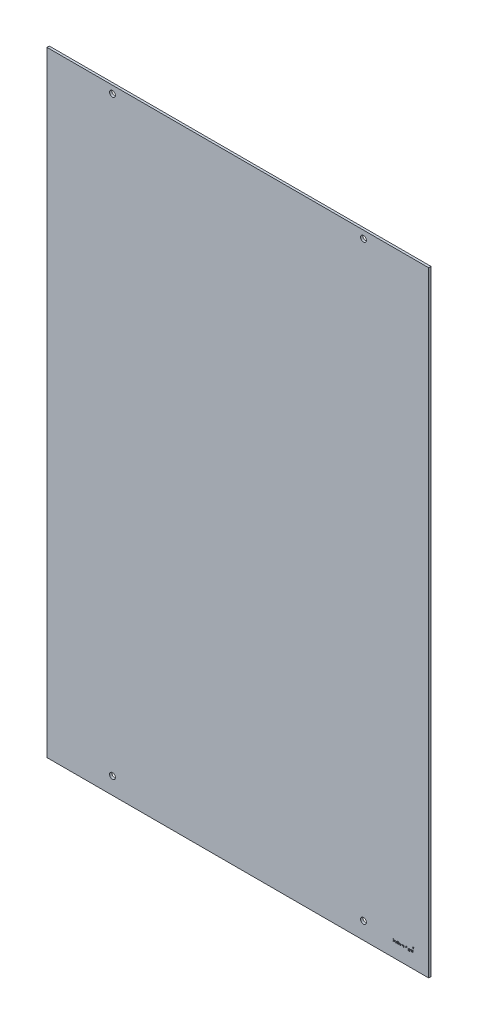
from build123d import *

# Parameters (mm, degrees)
SKETCH1_W           = 502.7676
SKETCH1_H           = 810.1076
BOSS_EXTRUDE1_DEPTH = 3.0734
SKETCH2_R           = 3.81
CUT_EXTRUDE1_DEPTH  = 4.0734
SKETCH3_W           = 0.284935897
SKETCH3_H           = 2.320192308
CUT_EXTRUDE2_DEPTH  = 1.27


with BuildPart() as part:
    # Sketch1 → Boss-Extrude1 (new body)
    with BuildSketch(Plane.XY):
        Rectangle(SKETCH1_W, SKETCH1_H)
    extrude(amount=BOSS_EXTRUDE1_DEPTH)

    # Sketch2 → Cut-Extrude1 (cut, through all)
    with BuildSketch(Plane(origin=(0, 0, 0), x_dir=(-1, 0, 0), z_dir=(0, 0, -1))):
        with Locations((-165.481, 395.1478)):
            Circle(SKETCH2_R)
        with Locations((165.1254, 395.1478)):
            Circle(SKETCH2_R)
        with Locations((165.1254, -382.8288)):
            Circle(SKETCH2_R)
        with Locations((-165.481, -382.8288)):
            Circle(SKETCH2_R)
    extrude(amount=-CUT_EXTRUDE1_DEPTH, mode=Mode.SUBTRACT)

    # Sketch3 → Cut-Extrude2 (cut)
    with BuildSketch(Plane.XY.offset(3.0734)):
        Polygon((231.0638, -379.564469266), (230.0478, -380.834469266), (230.5558, -380.834469266), (230.5558, -382.104469266), (231.5718, -382.104469266), (231.5718, -380.834469266), (232.0798, -380.834469266), align=None)
        Polygon((230.208992308, -383.382389744), (230.493928205, -383.382389744), (230.493928205, -384.318607692), (230.900979487, -384.318607692), (230.900979487, -384.60354359), (230.493928205, -384.60354359), (230.493928205, -386.6388), (230.208992308, -386.6388), (230.208992308, -384.60354359), (229.801941026, -384.60354359), (229.801941026, -384.318607692), (230.208992308, -384.318607692), align=None)
        with BuildLine():
            Line((227.237517949, -383.382389744), (227.522453846, -383.382389744))
            Line((227.522453846, -383.382389744), (227.522453846, -384.756823838))
            add(Edge.make_bspline(
                [(227.522453846, -384.756823838), (227.553040256, -384.718593226), (227.612593562, -384.644156265), (227.712829325, -384.54703647), (227.815763616, -384.462854864), (227.924951693, -384.395843806), (228.03839038, -384.342906085), (228.156558114, -384.305361577), (228.279476852, -384.282273796), (228.36295681, -384.279372374), (228.405246314, -384.277902564)],
                knots=[0, 0, 0, 0, 0.000146744, 0.000285718, 0.000417826, 0.00054491, 0.000668979, 0.000792481, 0.000915983, 0.001042781, 0.001042781, 0.001042781, 0.001042781], degree=3))
            add(Edge.make_bspline(
                [(228.405246314, -384.277902564), (228.448181742, -384.279485919), (228.532216731, -384.282584926), (228.654573486, -384.307089921), (228.768837994, -384.348961311), (228.87467058, -384.406262827), (228.969761555, -384.47763032), (229.053989556, -384.560027487), (229.122787995, -384.65552597), (229.169595765, -384.743751286), (229.200051642, -384.822254299), (229.219330085, -384.889597421), (229.235676072, -384.964638013), (229.249917975, -385.047337449), (229.259409938, -385.138092712), (229.267034127, -385.236494357), (229.272455625, -385.342536743), (229.272665723, -385.415942969), (229.272774359, -385.453899159)],
                knots=[0, 0, 0, 0, 0.000128741, 0.000251978, 0.000372501, 0.000492599, 0.000611662, 0.000728143, 0.000844672, 0.000963309, 0.001026736, 0.001096978, 0.001173207, 0.001257065, 0.001348583, 0.001446826, 0.001553163, 0.001667017, 0.001667017, 0.001667017, 0.001667017], degree=3))
            Line((229.272774359, -385.453899159), (229.272774359, -386.6388))
            Line((229.272774359, -386.6388), (228.987838462, -386.6388))
            Line((228.987838462, -386.6388), (228.987838462, -385.54739375))
            add(Edge.make_bspline(
                [(228.987838462, -385.54739375), (228.987665829, -385.515804614), (228.987335613, -385.455379973), (228.986244008, -385.368869289), (228.983807227, -385.290404938), (228.979869478, -385.220238389), (228.975728092, -385.158271821), (228.970028226, -385.104595221), (228.963396799, -385.059134868), (228.957437976, -385.031771241), (228.954765545, -385.019499119)],
                knots=[0, 0, 0, 0, 9.4769e-05, 0.000181277, 0.000259548, 0.000330249, 0.000392103, 0.000445834, 0.000492159, 0.000529829, 0.000529829, 0.000529829, 0.000529829], degree=3))
            add(Edge.make_bspline(
                [(228.954765545, -385.019499119), (228.944402123, -384.983490751), (228.924478503, -384.914264874), (228.878170696, -384.820228259), (228.820332164, -384.740050672), (228.749713577, -384.67481414), (228.667564204, -384.623640815), (228.573348379, -384.588200755), (228.467952831, -384.566204607), (228.393701853, -384.563991811), (228.355000921, -384.562838462)],
                knots=[0, 0, 0, 0, 0.000112235, 0.000215771, 0.000312707, 0.000407219, 0.000502346, 0.000601207, 0.000707732, 0.000823699, 0.000823699, 0.000823699, 0.000823699], degree=3))
            add(Edge.make_bspline(
                [(228.355000921, -384.562838462), (228.332079442, -384.563270104), (228.286718425, -384.564124313), (228.219454992, -384.57270035), (228.154205056, -384.586714544), (228.090340223, -384.605677947), (228.029214037, -384.631482113), (227.969044771, -384.661354499), (227.911537167, -384.697919844), (227.855670033, -384.738946076), (227.803674842, -384.784366501), (227.75529953, -384.832306239), (227.712175464, -384.883355671), (227.6731061, -384.936695776), (227.639380083, -384.993058189), (227.609940502, -385.051899392), (227.584961692, -385.113296767), (227.572549535, -385.155909858), (227.566339062, -385.17723149)],
                knots=[0, 0, 0, 0, 6.8737e-05, 0.000136029, 0.000203016, 0.000268809, 0.000335543, 0.000401817, 0.000470111, 0.000539693, 0.000609577, 0.000677037, 0.000743816, 0.000809842, 0.000875179, 0.000940599, 0.001007093, 0.001073681, 0.001073681, 0.001073681, 0.001073681], degree=3))
            add(Edge.make_bspline(
                [(227.566339062, -385.17723149), (227.562765439, -385.192671924), (227.554978074, -385.226318531), (227.54652819, -385.281812382), (227.538964617, -385.346297876), (227.532570576, -385.419677207), (227.528648919, -385.502219262), (227.524423229, -385.593360775), (227.52285023, -385.693672651), (227.522589923, -385.763427861), (227.522453846, -385.799892748)],
                knots=[0, 0, 0, 0, 4.7531e-05, 0.000103577, 0.000168266, 0.000242318, 0.000324485, 0.000416151, 0.000516024, 0.000625421, 0.000625421, 0.000625421, 0.000625421], degree=3))
            Line((227.522453846, -385.799892748), (227.522453846, -386.6388))
            Line((227.522453846, -386.6388), (227.237517949, -386.6388))
            Line((227.237517949, -386.6388), (227.237517949, -383.382389744))
        make_face()
        with BuildLine():
            Line((226.3013, -384.318607692), (226.586235897, -384.318607692))
            Line((226.586235897, -384.318607692), (226.586235897, -386.159878726))
            add(Edge.make_bspline(
                [(226.586235897, -386.159878726), (226.58598458, -386.199101401), (226.585499478, -386.274810612), (226.582006096, -386.384283051), (226.574639482, -386.485398715), (226.566285893, -386.578618764), (226.554269229, -386.663511106), (226.539594953, -386.740329056), (226.523052586, -386.809146331), (226.508519961, -386.851532436), (226.501645553, -386.871582452)],
                knots=[0, 0, 0, 0, 0.00011767, 0.000227132, 0.0003285, 0.000421785, 0.000507864, 0.000585575, 0.000656379, 0.000719936, 0.000719936, 0.000719936, 0.000719936], degree=3))
            add(Edge.make_bspline(
                [(226.501645553, -386.871582452), (226.491495315, -386.897644595), (226.471498324, -386.94898964), (226.434046357, -387.021773631), (226.392105602, -387.090304999), (226.344202335, -387.15420183), (226.290553177, -387.213143358), (226.232422109, -387.268410128), (226.168677007, -387.318832909), (226.099354318, -387.363541714), (226.026052065, -387.403807113), (225.948812387, -387.438683642), (225.868070832, -387.469060993), (225.783068923, -387.491814672), (225.695139353, -387.511531169), (225.603248112, -387.524362419), (225.507932075, -387.533095536), (225.443120909, -387.533903105), (225.410239303, -387.534312821)],
                knots=[0, 0, 0, 0, 8.3858e-05, 0.000165209, 0.000245167, 0.00032467, 0.000404375, 0.000484009, 0.000565064, 0.0006478, 0.000731198, 0.000815733, 0.000901862, 0.000989664, 0.001079485, 0.00117204, 0.0012678, 0.001366416, 0.001366416, 0.001366416, 0.001366416], degree=3))
            add(Edge.make_bspline(
                [(225.410239303, -387.534312821), (225.362265294, -387.533535866), (225.268559164, -387.532018264), (225.131938921, -387.514337219), (225.002185997, -387.489341467), (224.881014882, -387.451508686), (224.769191294, -387.405210845), (224.667478922, -387.352056852), (224.576790845, -387.291106551), (224.495035799, -387.221709577), (224.421247357, -387.139192523), (224.351826172, -387.041947857), (224.285005175, -386.928494322), (224.245845054, -386.845225218), (224.225338462, -386.801620513)],
                knots=[0, 0, 0, 0, 0.00014383, 0.000280939, 0.000412657, 0.0005398, 0.000660986, 0.000775358, 0.000883492, 0.000988144, 0.001096214, 0.001214661, 0.001346101, 0.001490599, 0.001490599, 0.001490599, 0.001490599], degree=3))
            Line((224.225338462, -386.801620513), (224.510274359, -386.801620513))
            add(Edge.make_bspline(
                [(224.510274359, -386.801620513), (224.533190792, -386.838002272), (224.577989596, -386.90912413), (224.661762861, -387.001211064), (224.753571457, -387.079908759), (224.856513741, -387.143327819), (224.971018043, -387.191143129), (225.097153251, -387.225229291), (225.235945765, -387.245636619), (225.332573003, -387.24809615), (225.382890545, -387.249376923)],
                knots=[0, 0, 0, 0, 0.000128773, 0.000251735, 0.000371772, 0.000490565, 0.000612829, 0.000742746, 0.000881626, 0.001032524, 0.001032524, 0.001032524, 0.001032524], degree=3))
            add(Edge.make_bspline(
                [(225.382890545, -387.249376923), (225.432571938, -387.248079574), (225.528352692, -387.245578414), (225.666085252, -387.225220184), (225.79181066, -387.191135711), (225.904804557, -387.14341239), (226.003733718, -387.084946664), (226.089016025, -387.01963231), (226.158090124, -386.945989543), (226.204547601, -386.878151762), (226.233426146, -386.817714159), (226.251815961, -386.765687161), (226.266760205, -386.706856336), (226.279260486, -386.641418919), (226.289575529, -386.569281415), (226.296109572, -386.490278885), (226.300831987, -386.404590876), (226.301140388, -386.345179244), (226.3013, -386.31443101)],
                knots=[0, 0, 0, 0, 0.000148992, 0.000287243, 0.000416547, 0.000538811, 0.000653999, 0.000760488, 0.000859928, 0.000955714, 0.001005782, 0.001060502, 0.001120973, 0.001187707, 0.001260294, 0.00133947, 0.001425447, 0.001517679, 0.001517679, 0.001517679, 0.001517679], degree=3))
            Line((226.3013, -386.31443101), (226.3013, -386.194223678))
            add(Edge.make_bspline(
                [(226.3013, -386.194223678), (226.272379272, -386.228642313), (226.215046523, -386.296874169), (226.116034305, -386.386283654), (226.007887531, -386.463287501), (225.890790318, -386.526441548), (225.767610984, -386.576952554), (225.639683675, -386.612279383), (225.508155168, -386.635103007), (225.419026432, -386.637558929), (225.373986298, -386.6388)],
                knots=[0, 0, 0, 0, 0.000134741, 0.000267112, 0.00039894, 0.000532134, 0.000665359, 0.000797455, 0.00092962, 0.001064637, 0.001064637, 0.001064637, 0.001064637], degree=3))
            add(Edge.make_bspline(
                [(225.373986298, -386.6388), (225.347464825, -386.638332797), (225.294735734, -386.637403921), (225.216399641, -386.62927703), (225.13921953, -386.617485314), (225.063375398, -386.600175723), (224.988757807, -386.577958228), (224.915490062, -386.550184472), (224.842978935, -386.518783615), (224.772542469, -386.481796858), (224.704882193, -386.440646765), (224.640508446, -386.396070771), (224.579758415, -386.348302181), (224.523210313, -386.296869957), (224.470938319, -386.241848538), (224.422239381, -386.183824458), (224.377918788, -386.121987485), (224.33706707, -386.057465174), (224.301636293, -385.989827764), (224.270535469, -385.920541921), (224.243494081, -385.849755791), (224.221935466, -385.777232384), (224.205469813, -385.703017422), (224.193214108, -385.627232486), (224.186262734, -385.549644206), (224.185178767, -385.497373411), (224.184633333, -385.471071635)],
                knots=[0, 0, 0, 0, 7.9543e-05, 0.000158144, 0.000236046, 0.000313655, 0.000391328, 0.000469416, 0.000548589, 0.000628244, 0.00070787, 0.000786028, 0.00086301, 0.000939549, 0.001015125, 0.001090533, 0.001166614, 0.0012432, 0.001319448, 0.001395457, 0.00147094, 0.001546602, 0.00162221, 0.001698855, 0.001776764, 0.001855671, 0.001855671, 0.001855671, 0.001855671], degree=3))
            add(Edge.make_bspline(
                [(224.184633333, -385.471071635), (224.185104291, -385.444761683), (224.186044383, -385.392243683), (224.1941642, -385.314338812), (224.205746772, -385.23747711), (224.224078105, -385.162450824), (224.246142108, -385.088405514), (224.273468492, -385.0158881), (224.30632408, -384.944876495), (224.343525782, -384.875318113), (224.385330637, -384.808146348), (224.431170816, -384.744350033), (224.481101659, -384.68439862), (224.534434326, -384.627687295), (224.591820017, -384.574763226), (224.653229046, -384.525754865), (224.718056087, -384.479840712), (224.786502057, -384.438011142), (224.857510831, -384.401015819), (224.929278365, -384.367258677), (225.002755336, -384.340467012), (225.076571854, -384.316860343), (225.152027919, -384.300136987), (225.22819834, -384.287235382), (225.30534389, -384.279375242), (225.357008302, -384.27839409), (225.382890545, -384.277902564)],
                knots=[0, 0, 0, 0, 7.8907e-05, 0.000157509, 0.000234782, 0.000311916, 0.000388979, 0.000466471, 0.000544164, 0.000623555, 0.000702973, 0.000781345, 0.000859033, 0.000936869, 0.001014737, 0.001093008, 0.001172416, 0.001252917, 0.00133343, 0.001412545, 0.001490633, 0.001567882, 0.001644872, 0.001722247, 0.001799582, 0.001877218, 0.001877218, 0.001877218, 0.001877218], degree=3))
            add(Edge.make_bspline(
                [(225.382890545, -384.277902564), (225.425572468, -384.279133261), (225.509856152, -384.281563508), (225.633890704, -384.30063269), (225.753581164, -384.331034688), (225.869602936, -384.374591724), (225.982901134, -384.434054973), (226.093102349, -384.512380362), (226.200525421, -384.610270455), (226.266817453, -384.685339125), (226.3013, -384.724386939)],
                knots=[0, 0, 0, 0, 0.000127998, 0.000252756, 0.000375547, 0.000497927, 0.000623674, 0.000758313, 0.000902407, 0.00105861, 0.00105861, 0.00105861, 0.00105861], degree=3))
            Line((226.3013, -384.724386939), (226.3013, -384.318607692))
        make_face()
        with BuildLine():
            add(Edge.make_bspline(
                [(225.405787179, -384.562838462), (225.36412147, -384.564254571), (225.281632199, -384.567058167), (225.160720631, -384.590992871), (225.04399227, -384.628499509), (224.933678774, -384.68215031), (224.830348753, -384.747550083), (224.738659452, -384.826780201), (224.658463564, -384.917264251), (224.590624755, -385.018184118), (224.536621301, -385.127061468), (224.498391199, -385.241824777), (224.473671535, -385.360619663), (224.470943165, -385.441693382), (224.469569231, -385.482519952)],
                knots=[0, 0, 0, 0, 0.000124893, 0.000247261, 0.000368342, 0.000491803, 0.000614243, 0.000734209, 0.000854054, 0.000975948, 0.001097972, 0.001217442, 0.001338059, 0.001460413, 0.001460413, 0.001460413, 0.001460413], degree=3))
            add(Edge.make_bspline(
                [(224.469569231, -385.482519952), (224.470227596, -385.513302278), (224.471522408, -385.573842111), (224.483971653, -385.662685773), (224.504092957, -385.747304343), (224.532610994, -385.82770294), (224.567946653, -385.904342718), (224.612389733, -385.976695738), (224.6646874, -386.044826436), (224.724430321, -386.108230897), (224.790267467, -386.16598049), (224.861677026, -386.216724284), (224.938562146, -386.258226723), (225.019031895, -386.294095912), (225.105038795, -386.320293352), (225.195344038, -386.340285673), (225.290586505, -386.351723617), (225.355512297, -386.353141298), (225.388614704, -386.353864103)],
                knots=[0, 0, 0, 0, 9.2301e-05, 0.00018153, 0.000268534, 0.000352818, 0.000437042, 0.000521251, 0.000606991, 0.000694281, 0.000782173, 0.000869345, 0.000956449, 0.001043889, 0.001133204, 0.001225645, 0.001321101, 0.001420393, 0.001420393, 0.001420393, 0.001420393], degree=3))
            add(Edge.make_bspline(
                [(225.388614704, -386.353864103), (225.422146113, -386.353167772), (225.487716428, -386.351806104), (225.583484349, -386.340100787), (225.674228335, -386.32121228), (225.759865181, -386.294394393), (225.840718226, -386.260175376), (225.915879198, -386.216871444), (225.98695969, -386.167555138), (226.051690147, -386.110031382), (226.110222783, -386.046635708), (226.161232122, -385.977652125), (226.204697372, -385.904118654), (226.240690687, -385.826043585), (226.268169136, -385.742820165), (226.286601286, -385.654656442), (226.299488833, -385.5619748), (226.300687101, -385.498466984), (226.3013, -385.465983494)],
                knots=[0, 0, 0, 0, 0.000100563, 0.00019665, 0.000288958, 0.000378273, 0.000465461, 0.000551765, 0.00063805, 0.000724567, 0.000810991, 0.000896473, 0.000981445, 0.001066823, 0.001153911, 0.001243732, 0.001336743, 0.001434128, 0.001434128, 0.001434128, 0.001434128], degree=3))
            add(Edge.make_bspline(
                [(226.3013, -385.465983494), (226.30008482, -385.42369444), (226.297710786, -385.341076491), (226.275306936, -385.220692494), (226.239184317, -385.107509483), (226.188523334, -385.001885419), (226.125039655, -384.90493947), (226.048575814, -384.818467126), (225.960450486, -384.742357063), (225.860916866, -384.678949416), (225.75383097, -384.627727201), (225.641779599, -384.589299022), (225.524929109, -384.56753275), (225.445729723, -384.56441223), (225.405787179, -384.562838462)],
                knots=[0, 0, 0, 0, 0.000126761, 0.000247646, 0.000365914, 0.000482266, 0.000597986, 0.000712444, 0.000827444, 0.000946177, 0.001065372, 0.00118283, 0.001300588, 0.001420403, 0.001420403, 0.001420403, 0.001420403], degree=3))
        make_face(mode=Mode.SUBTRACT)
        with BuildLine():
            add(Edge.make_bspline(
                [(223.430316426, -383.341684615), (223.447997834, -383.342504811), (223.482621427, -383.344110911), (223.532689605, -383.357864537), (223.578279895, -383.381177823), (223.618718267, -383.412455819), (223.653418193, -383.449239957), (223.677712123, -383.492112407), (223.693326225, -383.538429886), (223.695211771, -383.57073786), (223.696171795, -383.58718742)],
                knots=[0, 0, 0, 0, 5.2977e-05, 0.000103739, 0.000154369, 0.000205635, 0.000256504, 0.000304942, 0.000352409, 0.000401646, 0.000401646, 0.000401646, 0.000401646], degree=3))
            add(Edge.make_bspline(
                [(223.696171795, -383.58718742), (223.695190121, -383.60320997), (223.693249469, -383.634884654), (223.677724183, -383.680399161), (223.653211153, -383.722675904), (223.618740518, -383.759388619), (223.578273999, -383.790649325), (223.532691172, -383.813967195), (223.482621015, -383.827719605), (223.447997695, -383.829325873), (223.430316426, -383.830146154)],
                knots=[0, 0, 0, 0, 4.7972e-05, 9.4835e-05, 0.000142722, 0.000193592, 0.000244857, 0.000295488, 0.00034625, 0.000399227, 0.000399227, 0.000399227, 0.000399227], degree=3))
            add(Edge.make_bspline(
                [(223.430316426, -383.830146154), (223.412837348, -383.829357193), (223.378816606, -383.827821585), (223.329498113, -383.813697354), (223.284296555, -383.790641345), (223.243779316, -383.759593306), (223.210006213, -383.722450435), (223.18542416, -383.680424961), (223.169934731, -383.634878085), (223.167989246, -383.603207763), (223.167005128, -383.58718742)],
                knots=[0, 0, 0, 0, 5.2343e-05, 0.000101879, 0.000152509, 0.000203775, 0.000254217, 0.000302105, 0.000348968, 0.00039694, 0.00039694, 0.00039694, 0.00039694], degree=3))
            add(Edge.make_bspline(
                [(223.167005128, -383.58718742), (223.167967685, -383.570740149), (223.169858208, -383.538436672), (223.185435771, -383.492086178), (223.209801454, -383.449467244), (223.243801679, -383.412251255), (223.284290604, -383.381185753), (223.329499651, -383.358134363), (223.3788162, -383.344008934), (223.41283721, -383.342473491), (223.430316426, -383.341684615)],
                knots=[0, 0, 0, 0, 4.9237e-05, 9.6705e-05, 0.000145142, 0.000195584, 0.00024685, 0.00029748, 0.000347016, 0.000399359, 0.000399359, 0.000399359, 0.000399359], degree=3))
        make_face()
        with Locations((223.431588462, -385.478703846)):
            Rectangle(SKETCH3_W, SKETCH3_H)
        with BuildLine():
            Line((220.724697436, -383.4638), (221.360079046, -383.4638))
            add(Edge.make_bspline(
                [(221.360079046, -383.4638), (221.402479927, -383.463941139), (221.483894315, -383.464212141), (221.600528639, -383.465723226), (221.706507506, -383.470054248), (221.801775503, -383.47378132), (221.886330883, -383.480577582), (221.960432925, -383.487073311), (222.023740336, -383.495576561), (222.062063359, -383.503473623), (222.079414984, -383.507049199)],
                knots=[0, 0, 0, 0, 0.000127205, 0.000244248, 0.000349896, 0.000445402, 0.000530231, 0.00060434, 0.000668562, 0.000721699, 0.000721699, 0.000721699, 0.000721699], degree=3))
            add(Edge.make_bspline(
                [(222.079414984, -383.507049199), (222.10264385, -383.512788479), (222.148606048, -383.524144604), (222.214782179, -383.548147242), (222.277841602, -383.575923616), (222.337522371, -383.608547848), (222.393525553, -383.646262112), (222.446428592, -383.688415338), (222.496471548, -383.734776874), (222.541630598, -383.786515623), (222.584211024, -383.840795886), (222.620123563, -383.899491437), (222.651081156, -383.960870108), (222.675728696, -384.025556123), (222.695575143, -384.092922159), (222.709568946, -384.163578424), (222.717961095, -384.237203023), (222.718815493, -384.287420555), (222.719248718, -384.312883534)],
                knots=[0, 0, 0, 0, 7.1738e-05, 0.000141945, 0.000210849, 0.000278309, 0.000345694, 0.000413139, 0.000481086, 0.000550014, 0.000618962, 0.000687796, 0.000756061, 0.000824921, 0.000895163, 0.000966511, 0.001040751, 0.001117115, 0.001117115, 0.001117115, 0.001117115], degree=3))
            add(Edge.make_bspline(
                [(222.719248718, -384.312883534), (222.717916127, -384.355188236), (222.715315896, -384.437735667), (222.691072409, -384.557533752), (222.651360852, -384.669284059), (222.596639012, -384.77284588), (222.526952773, -384.866200537), (222.443200998, -384.948197593), (222.345336965, -385.016813799), (222.254233228, -385.064395987), (222.173756776, -385.094869554), (222.107505128, -385.116311108), (222.035235798, -385.132877319), (221.957641216, -385.147718296), (221.874398471, -385.158923047), (221.785707078, -385.167129601), (221.691503784, -385.172258631), (221.626789056, -385.173022449), (221.593497516, -385.173415385)],
                knots=[0, 0, 0, 0, 0.000126797, 0.000247415, 0.000364897, 0.000481551, 0.000597433, 0.000713022, 0.000831615, 0.000954788, 0.001020224, 0.001089619, 0.001163513, 0.001242474, 0.001326575, 0.001415367, 0.001509635, 0.001609508, 0.001609508, 0.001609508, 0.001609508], degree=3))
            Line((221.593497516, -385.173415385), (222.759953846, -386.6388))
            Line((222.759953846, -386.6388), (222.40760008, -386.6388))
            Line((222.40760008, -386.6388), (221.24114375, -385.173415385))
            Line((221.24114375, -385.173415385), (221.009633333, -385.173415385))
            Line((221.009633333, -385.173415385), (221.009633333, -386.6388))
            Line((221.009633333, -386.6388), (220.724697436, -386.6388))
            Line((220.724697436, -386.6388), (220.724697436, -383.4638))
        make_face()
        with BuildLine():
            Line((221.009633333, -383.789441026), (221.009633333, -384.847774359))
            Line((221.009633333, -384.847774359), (221.590953446, -384.852226482))
            add(Edge.make_bspline(
                [(221.590953446, -384.852226482), (221.618095195, -384.85223849), (221.670703636, -384.852261764), (221.746813525, -384.848638838), (221.817679626, -384.8445174), (221.88303088, -384.83821335), (221.942896481, -384.830088914), (221.997246505, -384.819926207), (222.046169674, -384.808086121), (222.103227634, -384.789760361), (222.166942201, -384.76072633), (222.23618574, -384.718484771), (222.295152146, -384.665354212), (222.344970493, -384.60459972), (222.385002192, -384.537801123), (222.413225269, -384.465759131), (222.431134485, -384.390292467), (222.433246808, -384.338423755), (222.434312821, -384.312247516)],
                knots=[0, 0, 0, 0, 8.1413e-05, 0.000157801, 0.000228539, 0.000294357, 0.000354712, 0.000409723, 0.000460165, 0.000505621, 0.000589315, 0.00066961, 0.000747992, 0.000826171, 0.000904597, 0.000980539, 0.001057529, 0.001135968, 0.001135968, 0.001135968, 0.001135968], degree=3))
            add(Edge.make_bspline(
                [(222.434312821, -384.312247516), (222.433222325, -384.286714553), (222.431061361, -384.236117536), (222.413418549, -384.16204396), (222.383583182, -384.092133227), (222.34337658, -384.02666973), (222.294391633, -383.96724667), (222.236953331, -383.916403895), (222.17263219, -383.874449024), (222.112514746, -383.847638978), (222.058780853, -383.831201683), (222.012126804, -383.819634556), (221.959411392, -383.810341359), (221.900378655, -383.802895475), (221.835280604, -383.796495633), (221.763788085, -383.792185091), (221.686375434, -383.789632514), (221.632720718, -383.789506341), (221.604945833, -383.789441026)],
                knots=[0, 0, 0, 0, 7.6536e-05, 0.000151667, 0.000226914, 0.000303706, 0.000381394, 0.000457083, 0.00053294, 0.00061095, 0.000653596, 0.000701416, 0.000755061, 0.00081407, 0.000879888, 0.000951261, 0.001028897, 0.001112218, 0.001112218, 0.001112218, 0.001112218], degree=3))
            Line((221.604945833, -383.789441026), (221.009633333, -383.789441026))
        make_face(mode=Mode.SUBTRACT)
        with BuildLine():
            Line((215.310915385, -384.318607692), (215.595851282, -384.318607692))
            Line((215.595851282, -384.318607692), (215.595851282, -384.721842869))
            add(Edge.make_bspline(
                [(215.595851282, -384.721842869), (215.621508865, -384.686566258), (215.670671254, -384.618972891), (215.751285096, -384.529900276), (215.831817712, -384.454309736), (215.889814423, -384.414628703), (215.917676202, -384.395565825)],
                knots=[0, 0, 0, 0, 0.000130766, 0.000250561, 0.000359957, 0.000461102, 0.000461102, 0.000461102, 0.000461102], degree=3))
            add(Edge.make_bspline(
                [(215.917676202, -384.395565825), (215.955653431, -384.377418101), (216.030944383, -384.341439715), (216.150160394, -384.304942129), (216.27214813, -384.28251293), (216.354524153, -384.279445541), (216.395961458, -384.277902564)],
                knots=[0, 0, 0, 0, 0.000126121, 0.000250038, 0.000372801, 0.000497059, 0.000497059, 0.000497059, 0.000497059], degree=3))
            add(Edge.make_bspline(
                [(216.395961458, -384.277902564), (216.42398582, -384.278850792), (216.479444523, -384.280727285), (216.561617234, -384.292937459), (216.641317546, -384.314043202), (216.718074558, -384.343441274), (216.790392603, -384.379043626), (216.856694947, -384.42081729), (216.916225478, -384.467713922), (216.968954111, -384.52185124), (217.016369584, -384.58474944), (217.059983966, -384.658104866), (217.10028398, -384.743564673), (217.122619024, -384.805582892), (217.134377925, -384.838234095)],
                knots=[0, 0, 0, 0, 8.4072e-05, 0.000166375, 0.000248601, 0.000330932, 0.000412566, 0.00049003, 0.000565619, 0.000639381, 0.000716086, 0.000801384, 0.000894984, 0.000999053, 0.000999053, 0.000999053, 0.000999053], degree=3))
            add(Edge.make_bspline(
                [(217.134377925, -384.838234095), (217.146815988, -384.815805514), (217.171292351, -384.771669218), (217.212391036, -384.709204937), (217.255451109, -384.650778776), (217.300839542, -384.596344377), (217.348396131, -384.54617055), (217.398344687, -384.50009141), (217.450400882, -384.457909074), (217.522783842, -384.408630208), (217.616956707, -384.356286993), (217.735690926, -384.310904047), (217.859198581, -384.282858702), (217.943034636, -384.279565526), (217.985369511, -384.277902564)],
                knots=[0, 0, 0, 0, 7.6916e-05, 0.00015136, 0.000224122, 0.000294562, 0.000363845, 0.000431358, 0.000498307, 0.000564639, 0.000693874, 0.000820499, 0.000944881, 0.001071761, 0.001071761, 0.001071761, 0.001071761], degree=3))
            add(Edge.make_bspline(
                [(217.985369511, -384.277902564), (218.024269124, -384.279369614), (218.100399443, -384.282240774), (218.211231677, -384.304786425), (218.314593172, -384.343501148), (218.410275948, -384.396327375), (218.496599493, -384.462711349), (218.571635002, -384.541695223), (218.634926689, -384.632720317), (218.676273026, -384.718347335), (218.704317587, -384.793944387), (218.72160885, -384.858357237), (218.736884859, -384.92925186), (218.749567846, -385.006713026), (218.758837532, -385.091014363), (218.765705253, -385.182017915), (218.770353519, -385.279794409), (218.770681971, -385.347254541), (218.770851282, -385.382029167)],
                knots=[0, 0, 0, 0, 0.000116641, 0.000228278, 0.000337557, 0.000446591, 0.000554977, 0.000662946, 0.000772158, 0.00088622, 0.000947188, 0.001013849, 0.001086078, 0.001164708, 0.001249203, 0.001340422, 0.00143847, 0.001542785, 0.001542785, 0.001542785, 0.001542785], degree=3))
            Line((218.770851282, -385.382029167), (218.770851282, -386.6388))
            Line((218.770851282, -386.6388), (218.485915385, -386.6388))
            Line((218.485915385, -386.6388), (218.485915385, -385.380757131))
            add(Edge.make_bspline(
                [(218.485915385, -385.380757131), (218.485844734, -385.351074896), (218.485708953, -385.294030155), (218.483265445, -385.212158289), (218.47866141, -385.137529136), (218.473277844, -385.070244456), (218.465799532, -385.010147341), (218.456142151, -384.957358504), (218.445911684, -384.911462689), (218.428915463, -384.860584632), (218.401748448, -384.804459512), (218.360366876, -384.743931697), (218.30823328, -384.691244114), (218.248035138, -384.645507498), (218.179501906, -384.608320409), (218.103968907, -384.581762886), (218.021905089, -384.565322847), (217.965097274, -384.563684533), (217.935760136, -384.562838462)],
                knots=[0, 0, 0, 0, 8.9045e-05, 0.00017113, 0.000245678, 0.000313338, 0.000373609, 0.000427253, 0.000474306, 0.000514531, 0.000587924, 0.000660612, 0.000733474, 0.000809288, 0.000886697, 0.000966359, 0.001048684, 0.001136601, 0.001136601, 0.001136601, 0.001136601], degree=3))
            add(Edge.make_bspline(
                [(217.935760136, -384.562838462), (217.89977382, -384.564123119), (217.82865118, -384.566662089), (217.724832774, -384.592582674), (217.625073352, -384.631662616), (217.532349624, -384.688297773), (217.447052986, -384.756159646), (217.373665512, -384.836849637), (217.313039172, -384.928135356), (217.271987351, -385.012632722), (217.24605277, -385.08853286), (217.228928711, -385.154842619), (217.215608777, -385.23020947), (217.20311694, -385.314126979), (217.194963787, -385.407172786), (217.187553906, -385.508916478), (217.184087838, -385.61966407), (217.183603007, -385.696432566), (217.183351282, -385.736290986)],
                knots=[0, 0, 0, 0, 0.000107758, 0.00021297, 0.000319147, 0.000428114, 0.000537576, 0.000645175, 0.000753838, 0.000865349, 0.000925892, 0.00099423, 0.001070573, 0.001155393, 0.001248678, 0.001350681, 0.001461413, 0.001580991, 0.001580991, 0.001580991, 0.001580991], degree=3))
            Line((217.183351282, -385.736290986), (217.183351282, -386.6388))
            Line((217.183351282, -386.6388), (216.898415385, -386.6388))
            Line((216.898415385, -386.6388), (216.898415385, -385.4589873))
            add(Edge.make_bspline(
                [(216.898415385, -385.4589873), (216.898343329, -385.425701218), (216.898204702, -385.361662141), (216.8957769, -385.269828736), (216.891162608, -385.186298042), (216.88582811, -385.111167143), (216.87815352, -385.04457258), (216.869436093, -384.986157335), (216.859141282, -384.936067854), (216.842096172, -384.881128212), (216.816048047, -384.820602803), (216.774148695, -384.756067734), (216.72189039, -384.699581674), (216.660593953, -384.651359095), (216.591645941, -384.611497894), (216.515460999, -384.582777977), (216.432725114, -384.566064514), (216.375686052, -384.563934092), (216.346352083, -384.562838462)],
                knots=[0, 0, 0, 0, 9.9857e-05, 0.000192114, 0.000275552, 0.00035082, 0.000418036, 0.000476595, 0.00052799, 0.000571244, 0.000648997, 0.000724854, 0.000800924, 0.000878799, 0.000958003, 0.00103892, 0.001121993, 0.00120995, 0.00120995, 0.00120995, 0.00120995], degree=3))
            add(Edge.make_bspline(
                [(216.346352083, -384.562838462), (216.311865949, -384.564226807), (216.243136307, -384.566993731), (216.14216952, -384.59189868), (216.04466465, -384.630909519), (215.952177173, -384.685029498), (215.867201339, -384.752066519), (215.792808125, -384.830910746), (215.730267405, -384.920580941), (215.688782116, -385.004187324), (215.662022786, -385.078185937), (215.644247018, -385.141097154), (215.628971072, -385.210947379), (215.617619066, -385.287952116), (215.606660404, -385.371609823), (215.60137148, -385.462337253), (215.596226563, -385.560056575), (215.595979444, -385.627523098), (215.595851282, -385.662512941)],
                knots=[0, 0, 0, 0, 0.000103317, 0.000205907, 0.000310077, 0.000417526, 0.000526194, 0.000633726, 0.00074153, 0.00085303, 0.000912585, 0.000977409, 0.001049016, 0.001126918, 0.001210855, 0.001302028, 0.00139944, 0.001504391, 0.001504391, 0.001504391, 0.001504391], degree=3))
            Line((215.595851282, -385.662512941), (215.595851282, -386.6388))
            Line((215.595851282, -386.6388), (215.310915385, -386.6388))
            Line((215.310915385, -386.6388), (215.310915385, -384.318607692))
        make_face()
        with BuildLine():
            add(Edge.make_bspline(
                [(213.541514343, -384.277902564), (213.585049283, -384.278829565), (213.670410662, -384.280647188), (213.795422101, -384.300073621), (213.914752332, -384.329780159), (214.028858378, -384.370847933), (214.136278874, -384.425895131), (214.238578503, -384.491580702), (214.335476789, -384.569397769), (214.393554823, -384.629594017), (214.423034776, -384.660149159)],
                knots=[0, 0, 0, 0, 0.000130509, 0.000255897, 0.000378531, 0.000499054, 0.000618803, 0.000739829, 0.000863296, 0.000990571, 0.000990571, 0.000990571, 0.000990571], degree=3))
            add(Edge.make_bspline(
                [(214.423034776, -384.660149159), (214.448418405, -384.689371846), (214.498694422, -384.74725168), (214.563161181, -384.841100701), (214.618697882, -384.938292078), (214.663204997, -385.040116438), (214.698297839, -385.14568489), (214.72321315, -385.255360286), (214.738033083, -385.368900415), (214.740031489, -385.44601104), (214.74104359, -385.485064022)],
                knots=[0, 0, 0, 0, 0.000116043, 0.000229841, 0.000340916, 0.00045141, 0.000562633, 0.000674184, 0.000788337, 0.000905475, 0.000905475, 0.000905475, 0.000905475], degree=3))
            add(Edge.make_bspline(
                [(214.74104359, -385.485064022), (214.740153377, -385.52434336), (214.738394274, -385.601961164), (214.721753993, -385.716278732), (214.695872223, -385.827126892), (214.658831912, -385.934041565), (214.611335627, -386.037349558), (214.553377647, -386.136599649), (214.484551251, -386.231987656), (214.40653334, -386.322703609), (214.320307709, -386.406311532), (214.226766632, -386.479180748), (214.12774833, -386.541611703), (214.021936145, -386.591900451), (213.910296353, -386.631551394), (213.792588156, -386.659400694), (213.668994413, -386.676238793), (213.584605434, -386.678401034), (213.541514343, -386.679505128)],
                knots=[0, 0, 0, 0, 0.000117773, 0.000232725, 0.000345804, 0.000458844, 0.000571541, 0.000686407, 0.000803078, 0.000923941, 0.00104494, 0.001162753, 0.001279048, 0.001395399, 0.001513481, 0.001633808, 0.001757668, 0.001886907, 0.001886907, 0.001886907, 0.001886907], degree=3))
            add(Edge.make_bspline(
                [(213.541514343, -386.679505128), (213.498212133, -386.678397329), (213.413402568, -386.676227648), (213.28937257, -386.659466113), (213.171453415, -386.631564228), (213.059667472, -386.591770146), (212.953400361, -386.541610095), (212.853808325, -386.479369491), (212.760191258, -386.406289922), (212.673947387, -386.322709465), (212.595934366, -386.231986147), (212.527106709, -386.136600041), (212.469149056, -386.037349456), (212.421652685, -385.934041592), (212.384612398, -385.827126885), (212.358730621, -385.716278734), (212.342090342, -385.601961164), (212.340331239, -385.52434336), (212.339441026, -385.485064022)],
                knots=[0, 0, 0, 0, 0.000129874, 0.000254364, 0.000374691, 0.000492773, 0.000609698, 0.000726534, 0.000844346, 0.000965345, 0.001086209, 0.001202879, 0.001317745, 0.001430442, 0.001543482, 0.001656561, 0.001771513, 0.001889286, 0.001889286, 0.001889286, 0.001889286], degree=3))
            add(Edge.make_bspline(
                [(212.339441026, -385.485064022), (212.340460029, -385.446223299), (212.342477479, -385.369325341), (212.357282513, -385.25599865), (212.382100632, -385.146508876), (212.417235541, -385.041347908), (212.462152893, -384.939969763), (212.516909204, -384.842538237), (212.582033564, -384.74911359), (212.63210962, -384.69130856), (212.65744984, -384.662057212)],
                knots=[0, 0, 0, 0, 0.000116502, 0.000230655, 0.000342206, 0.000452826, 0.000562738, 0.000674367, 0.000787643, 0.000903686, 0.000903686, 0.000903686, 0.000903686], degree=3))
            add(Edge.make_bspline(
                [(212.65744984, -384.662057212), (212.686885347, -384.631237088), (212.744775452, -384.570623892), (212.842156084, -384.493033674), (212.94420405, -384.425981236), (213.052811662, -384.372027811), (213.166823969, -384.329538585), (213.28676571, -384.29999701), (213.412201356, -384.280717181), (213.497980441, -384.27885012), (213.541514343, -384.277902564)],
                knots=[0, 0, 0, 0, 0.000127724, 0.000251192, 0.000372563, 0.000493448, 0.000614191, 0.000736825, 0.000863471, 0.00099398, 0.00099398, 0.00099398, 0.00099398], degree=3))
        make_face()
        with BuildLine():
            add(Edge.make_bspline(
                [(213.540242308, -384.562838462), (213.509456046, -384.563713484), (213.448678265, -384.56544094), (213.359216213, -384.578579911), (213.273091931, -384.599396575), (213.190142022, -384.628973112), (213.110646216, -384.667162828), (213.034528401, -384.714069697), (212.961564687, -384.769072451), (212.893182387, -384.832085017), (212.830424147, -384.900918105), (212.775561982, -384.974259116), (212.728912064, -385.050918445), (212.69004992, -385.130975808), (212.661105542, -385.215242497), (212.6400843, -385.302764213), (212.626957725, -385.393719269), (212.62524651, -385.45555105), (212.624376923, -385.486972075)],
                knots=[0, 0, 0, 0, 9.233e-05, 0.000182276, 0.000270667, 0.000357773, 0.00044596, 0.000534752, 0.000625576, 0.000719657, 0.000813309, 0.000904642, 0.000993977, 0.001082163, 0.001171069, 0.001260696, 0.001351902, 0.001446138, 0.001446138, 0.001446138, 0.001446138], degree=3))
            add(Edge.make_bspline(
                [(212.624376923, -385.486972075), (212.625834542, -385.527568557), (212.628727642, -385.608144982), (212.652254606, -385.726809358), (212.69161216, -385.840730038), (212.744759193, -385.949239188), (212.81134912, -386.049634754), (212.889805244, -386.139143887), (212.979285544, -386.216419587), (213.078723369, -386.280537211), (213.186087643, -386.331482133), (213.29971302, -386.367585489), (213.418222793, -386.39105481), (213.49921317, -386.393387505), (213.540242308, -386.394569231)],
                knots=[0, 0, 0, 0, 0.000121719, 0.000241589, 0.000361264, 0.000482436, 0.000603094, 0.00072162, 0.000838414, 0.000956612, 0.001075534, 0.001193802, 0.001313553, 0.001436504, 0.001436504, 0.001436504, 0.001436504], degree=3))
            add(Edge.make_bspline(
                [(213.540242308, -386.394569231), (213.581269085, -386.393380619), (213.662254804, -386.391034334), (213.780599915, -386.36770369), (213.893914732, -386.331323941), (214.001167491, -386.280594507), (214.100560053, -386.216176102), (214.190683898, -386.139580246), (214.268470138, -386.049397681), (214.334994194, -385.949106208), (214.389011597, -385.84089826), (214.42818493, -385.726788332), (214.451768454, -385.608150337), (214.45465392, -385.527570351), (214.456107692, -385.486972075)],
                knots=[0, 0, 0, 0, 0.000122951, 0.000242701, 0.000360364, 0.000479286, 0.000597484, 0.00071476, 0.000832868, 0.000953525, 0.00107498, 0.001194654, 0.001314525, 0.001436243, 0.001436243, 0.001436243, 0.001436243], degree=3))
            add(Edge.make_bspline(
                [(214.456107692, -385.486972075), (214.455238404, -385.455550862), (214.453527779, -385.393718712), (214.440396918, -385.302766343), (214.419391536, -385.215234681), (214.390388712, -385.131004649), (214.351695428, -385.050711163), (214.304145908, -384.974484196), (214.249507764, -384.900664044), (214.185992233, -384.832307527), (214.117681311, -384.769047886), (214.044688027, -384.714048369), (213.968683082, -384.667368979), (213.889418225, -384.62864646), (213.806457681, -384.599665659), (213.720454071, -384.578459715), (213.631373722, -384.565496465), (213.570813733, -384.563730129), (213.540242308, -384.562838462)],
                knots=[0, 0, 0, 0, 9.4236e-05, 0.000185442, 0.000275068, 0.000363974, 0.000452161, 0.000541828, 0.00063316, 0.000727242, 0.000821323, 0.000912146, 0.001000939, 0.001088552, 0.001176258, 0.001264031, 0.001353977, 0.001445672, 0.001445672, 0.001445672, 0.001445672], degree=3))
        make_face(mode=Mode.SUBTRACT)
        Polygon((211.240402564, -383.382389744), (211.525338462, -383.382389744), (211.525338462, -384.318607692), (211.932389744, -384.318607692), (211.932389744, -384.60354359), (211.525338462, -384.60354359), (211.525338462, -386.6388), (211.240402564, -386.6388), (211.240402564, -384.60354359), (210.833351282, -384.60354359), (210.833351282, -384.318607692), (211.240402564, -384.318607692), align=None)
        Polygon((209.775017949, -383.382389744), (210.059953846, -383.382389744), (210.059953846, -384.318607692), (210.467005128, -384.318607692), (210.467005128, -384.60354359), (210.059953846, -384.60354359), (210.059953846, -386.6388), (209.775017949, -386.6388), (209.775017949, -384.60354359), (209.367966667, -384.60354359), (209.367966667, -384.318607692), (209.775017949, -384.318607692), align=None)
        with BuildLine():
            add(Edge.make_bspline(
                [(207.72068101, -384.277902564), (207.76421595, -384.278829565), (207.849577329, -384.280647188), (207.974588768, -384.300073621), (208.093918998, -384.329780159), (208.208025044, -384.370847933), (208.315445541, -384.425895131), (208.417745169, -384.491580702), (208.514643456, -384.569397769), (208.57272149, -384.629594017), (208.602201442, -384.660149159)],
                knots=[0, 0, 0, 0, 0.000130509, 0.000255897, 0.000378531, 0.000499054, 0.000618803, 0.000739829, 0.000863296, 0.000990571, 0.000990571, 0.000990571, 0.000990571], degree=3))
            add(Edge.make_bspline(
                [(208.602201442, -384.660149159), (208.627585072, -384.689371846), (208.677861088, -384.74725168), (208.742327848, -384.841100701), (208.797864549, -384.938292078), (208.842371663, -385.040116438), (208.877464506, -385.14568489), (208.902379816, -385.255360286), (208.91719975, -385.368900415), (208.919198156, -385.44601104), (208.920210256, -385.485064022)],
                knots=[0, 0, 0, 0, 0.000116043, 0.000229841, 0.000340916, 0.00045141, 0.000562633, 0.000674184, 0.000788337, 0.000905475, 0.000905475, 0.000905475, 0.000905475], degree=3))
            add(Edge.make_bspline(
                [(208.920210256, -385.485064022), (208.919320043, -385.52434336), (208.917560941, -385.601961164), (208.90092066, -385.716278732), (208.875038889, -385.827126892), (208.837998579, -385.934041565), (208.790502294, -386.037349558), (208.732544313, -386.136599649), (208.663717918, -386.231987656), (208.585700006, -386.322703609), (208.499474376, -386.406311532), (208.405933298, -386.479180748), (208.306914996, -386.541611703), (208.201102812, -386.591900451), (208.08946302, -386.631551394), (207.971754822, -386.659400694), (207.84816108, -386.676238793), (207.763772101, -386.678401034), (207.72068101, -386.679505128)],
                knots=[0, 0, 0, 0, 0.000117773, 0.000232725, 0.000345804, 0.000458844, 0.000571541, 0.000686407, 0.000803078, 0.000923941, 0.00104494, 0.001162753, 0.001279048, 0.001395399, 0.001513481, 0.001633808, 0.001757668, 0.001886907, 0.001886907, 0.001886907, 0.001886907], degree=3))
            add(Edge.make_bspline(
                [(207.72068101, -386.679505128), (207.6773788, -386.678397329), (207.592569234, -386.676227648), (207.468539236, -386.659466113), (207.350620082, -386.631564228), (207.238834139, -386.591770146), (207.132567028, -386.541610095), (207.032974991, -386.479369491), (206.939357925, -386.406289922), (206.853114054, -386.322709465), (206.775101033, -386.231986147), (206.706273375, -386.136600041), (206.648315722, -386.037349456), (206.600819352, -385.934041592), (206.563779064, -385.827126885), (206.537897287, -385.716278734), (206.521257008, -385.601961164), (206.519497906, -385.52434336), (206.518607692, -385.485064022)],
                knots=[0, 0, 0, 0, 0.000129874, 0.000254364, 0.000374691, 0.000492773, 0.000609698, 0.000726534, 0.000844346, 0.000965345, 0.001086209, 0.001202879, 0.001317745, 0.001430442, 0.001543482, 0.001656561, 0.001771513, 0.001889286, 0.001889286, 0.001889286, 0.001889286], degree=3))
            add(Edge.make_bspline(
                [(206.518607692, -385.485064022), (206.519626695, -385.446223299), (206.521644146, -385.369325341), (206.536449179, -385.25599865), (206.561267298, -385.146508876), (206.596402208, -385.041347908), (206.64131956, -384.939969763), (206.696075871, -384.842538237), (206.76120023, -384.74911359), (206.811276286, -384.69130856), (206.836616506, -384.662057212)],
                knots=[0, 0, 0, 0, 0.000116502, 0.000230655, 0.000342206, 0.000452826, 0.000562738, 0.000674367, 0.000787643, 0.000903686, 0.000903686, 0.000903686, 0.000903686], degree=3))
            add(Edge.make_bspline(
                [(206.836616506, -384.662057212), (206.866052014, -384.631237088), (206.923942119, -384.570623892), (207.021322751, -384.493033674), (207.123370717, -384.425981236), (207.231978328, -384.372027811), (207.345990635, -384.329538585), (207.465932377, -384.29999701), (207.591368023, -384.280717181), (207.677147108, -384.27885012), (207.72068101, -384.277902564)],
                knots=[0, 0, 0, 0, 0.000127724, 0.000251192, 0.000372563, 0.000493448, 0.000614191, 0.000736825, 0.000863471, 0.00099398, 0.00099398, 0.00099398, 0.00099398], degree=3))
        make_face()
        with BuildLine():
            add(Edge.make_bspline(
                [(207.719408974, -384.562838462), (207.688622713, -384.563713484), (207.627844932, -384.56544094), (207.53838288, -384.578579911), (207.452258597, -384.599396575), (207.369308689, -384.628973112), (207.289812882, -384.667162828), (207.213695067, -384.714069697), (207.140731354, -384.769072451), (207.072349054, -384.832085017), (207.009590813, -384.900918105), (206.954728649, -384.974259116), (206.908078731, -385.050918445), (206.869216587, -385.130975808), (206.840272209, -385.215242497), (206.819250967, -385.302764213), (206.806124392, -385.393719269), (206.804413177, -385.45555105), (206.80354359, -385.486972075)],
                knots=[0, 0, 0, 0, 9.233e-05, 0.000182276, 0.000270667, 0.000357773, 0.00044596, 0.000534752, 0.000625576, 0.000719657, 0.000813309, 0.000904642, 0.000993977, 0.001082163, 0.001171069, 0.001260696, 0.001351902, 0.001446138, 0.001446138, 0.001446138, 0.001446138], degree=3))
            add(Edge.make_bspline(
                [(206.80354359, -385.486972075), (206.805001208, -385.527568557), (206.807894309, -385.608144982), (206.831421273, -385.726809358), (206.870778827, -385.840730038), (206.923925859, -385.949239188), (206.990515786, -386.049634754), (207.068971911, -386.139143887), (207.158452211, -386.216419587), (207.257890036, -386.280537211), (207.36525431, -386.331482133), (207.478879687, -386.367585489), (207.597389459, -386.39105481), (207.678379837, -386.393387505), (207.719408974, -386.394569231)],
                knots=[0, 0, 0, 0, 0.000121719, 0.000241589, 0.000361264, 0.000482436, 0.000603094, 0.00072162, 0.000838414, 0.000956612, 0.001075534, 0.001193802, 0.001313553, 0.001436504, 0.001436504, 0.001436504, 0.001436504], degree=3))
            add(Edge.make_bspline(
                [(207.719408974, -386.394569231), (207.760435752, -386.393380619), (207.841421471, -386.391034334), (207.959766582, -386.36770369), (208.073081399, -386.331323941), (208.180334158, -386.280594507), (208.279726719, -386.216176102), (208.369850565, -386.139580246), (208.447636805, -386.049397681), (208.514160861, -385.949106208), (208.568178263, -385.84089826), (208.607351596, -385.726788332), (208.630935121, -385.608150337), (208.633820587, -385.527570351), (208.635274359, -385.486972075)],
                knots=[0, 0, 0, 0, 0.000122951, 0.000242701, 0.000360364, 0.000479286, 0.000597484, 0.00071476, 0.000832868, 0.000953525, 0.00107498, 0.001194654, 0.001314525, 0.001436243, 0.001436243, 0.001436243, 0.001436243], degree=3))
            add(Edge.make_bspline(
                [(208.635274359, -385.486972075), (208.634405071, -385.455550862), (208.632694445, -385.393718712), (208.619563585, -385.302766343), (208.598558203, -385.215234681), (208.569555378, -385.131004649), (208.530862094, -385.050711163), (208.483312575, -384.974484196), (208.42867443, -384.900664044), (208.365158899, -384.832307527), (208.296847978, -384.769047886), (208.223854693, -384.714048369), (208.147849748, -384.667368979), (208.068584891, -384.62864646), (207.985624348, -384.599665659), (207.899620738, -384.578459715), (207.810540389, -384.565496465), (207.7499804, -384.563730129), (207.719408974, -384.562838462)],
                knots=[0, 0, 0, 0, 9.4236e-05, 0.000185442, 0.000275068, 0.000363974, 0.000452161, 0.000541828, 0.00063316, 0.000727242, 0.000821323, 0.000912146, 0.001000939, 0.001088552, 0.001176258, 0.001264031, 0.001353977, 0.001445672, 0.001445672, 0.001445672, 0.001445672], degree=3))
        make_face(mode=Mode.SUBTRACT)
        with BuildLine():
            Line((204.157710256, -383.4638), (204.777191426, -383.4638))
            add(Edge.make_bspline(
                [(204.777191426, -383.4638), (204.807515831, -383.463959431), (204.866292076, -383.464268447), (204.95176257, -383.469061002), (205.031816848, -383.475595759), (205.106478127, -383.485964486), (205.175711907, -383.498475599), (205.239726835, -383.513626532), (205.298319348, -383.531793531), (205.368271616, -383.560682658), (205.448028216, -383.603611532), (205.534386758, -383.66704673), (205.608232032, -383.744636893), (205.671901049, -383.832160445), (205.722520636, -383.928440752), (205.759141355, -384.031183016), (205.782325999, -384.139062025), (205.784710365, -384.213124051), (205.785915385, -384.250553806)],
                knots=[0, 0, 0, 0, 9.0959e-05, 0.000176302, 0.000256745, 0.000331852, 0.000402335, 0.000467743, 0.000529095, 0.000586142, 0.000694565, 0.000800018, 0.00090617, 0.001014562, 0.001123809, 0.001231237, 0.001341005, 0.001453163, 0.001453163, 0.001453163, 0.001453163], degree=3))
            add(Edge.make_bspline(
                [(205.785915385, -384.250553806), (205.784923679, -384.285617196), (205.782974885, -384.354520063), (205.764339667, -384.455298291), (205.735165347, -384.551229754), (205.694611299, -384.641964346), (205.641904489, -384.725451981), (205.579440157, -384.802366144), (205.504077629, -384.869450317), (205.447614118, -384.906954236), (205.418933213, -384.926004527)],
                knots=[0, 0, 0, 0, 0.000105099, 0.000206529, 0.000306317, 0.000405381, 0.000503676, 0.000601724, 0.00070171, 0.000804929, 0.000804929, 0.000804929, 0.000804929], degree=3))
            add(Edge.make_bspline(
                [(205.418933213, -384.926004527), (205.455001601, -384.939852062), (205.524009362, -384.966345826), (205.61897453, -385.013186569), (205.70079414, -385.064133626), (205.770097265, -385.119770376), (205.829367852, -385.179740511), (205.88112302, -385.244923365), (205.925283981, -385.316169238), (205.963123562, -385.392735302), (205.992649933, -385.473839741), (206.014762361, -385.558721803), (206.027432833, -385.647077113), (206.029235907, -385.707207422), (206.030146154, -385.737563021)],
                knots=[0, 0, 0, 0, 0.000115862, 0.000221672, 0.000317136, 0.000404447, 0.000487649, 0.000569596, 0.000653599, 0.000738647, 0.000825372, 0.000912066, 0.001001383, 0.001092443, 0.001092443, 0.001092443, 0.001092443], degree=3))
            add(Edge.make_bspline(
                [(206.030146154, -385.737563021), (206.029260015, -385.768557255), (206.027516512, -385.829539279), (206.014653252, -385.919124293), (205.992873562, -386.004735852), (205.962873308, -386.086927696), (205.923718922, -386.165540818), (205.876068555, -386.240664279), (205.819252779, -386.311543279), (205.755695748, -386.378965423), (205.683793659, -386.439587773), (205.606218653, -386.493577021), (205.521993777, -386.537978092), (205.432502325, -386.575276197), (205.33674041, -386.603767013), (205.235138044, -386.623699276), (205.127782856, -386.63712956), (205.054114011, -386.638233739), (205.016334054, -386.6388)],
                knots=[0, 0, 0, 0, 9.2965e-05, 0.000182912, 0.000270839, 0.000357564, 0.000444886, 0.000533812, 0.000623905, 0.000717027, 0.000811331, 0.000905539, 0.001000006, 0.001096388, 0.001195991, 0.001299146, 0.001406751, 0.001520027, 0.001520027, 0.001520027, 0.001520027], degree=3))
            Line((205.016334054, -386.6388), (204.157710256, -386.6388))
            Line((204.157710256, -386.6388), (204.157710256, -383.4638))
        make_face()
        with BuildLine():
            Line((204.442646154, -383.789441026), (204.442646154, -384.807069231))
            Line((204.442646154, -384.807069231), (204.63408746, -384.807069231))
            add(Edge.make_bspline(
                [(204.63408746, -384.807069231), (204.662071724, -384.806706443), (204.716143026, -384.806005464), (204.794447504, -384.803997488), (204.867132341, -384.798374977), (204.934072076, -384.792754083), (204.995161293, -384.783614992), (205.050264653, -384.772736424), (205.100246951, -384.761231217), (205.157886396, -384.741664611), (205.223266857, -384.712747006), (205.292965458, -384.667868983), (205.354410299, -384.614416177), (205.406296319, -384.552738661), (205.44876101, -384.484824336), (205.478255595, -384.411756808), (205.498255631, -384.335357117), (205.500062234, -384.282907702), (205.500979487, -384.256277965)],
                knots=[0, 0, 0, 0, 8.3964e-05, 0.000162235, 0.00023492, 0.000302637, 0.000363711, 0.000420091, 0.000471151, 0.00051741, 0.000602525, 0.000684916, 0.00076515, 0.000845934, 0.000925893, 0.001004319, 0.001081603, 0.001161311, 0.001161311, 0.001161311, 0.001161311], degree=3))
            add(Edge.make_bspline(
                [(205.500979487, -384.256277965), (205.500502167, -384.238656015), (205.49956585, -384.204088636), (205.491897497, -384.153697436), (205.478864055, -384.106304889), (205.462123374, -384.061261518), (205.438729349, -384.019975768), (205.411185351, -383.981020155), (205.377906189, -383.945721304), (205.340026341, -383.912728974), (205.296475661, -383.883478581), (205.247280132, -383.857860174), (205.191774168, -383.837231041), (205.130893221, -383.819164245), (205.063700163, -383.806474864), (204.99097039, -383.795903577), (204.91210818, -383.790521733), (204.85754798, -383.789809296), (204.829344872, -383.789441026)],
                knots=[0, 0, 0, 0, 5.2851e-05, 0.000103672, 0.000152426, 0.000200145, 0.000247403, 0.000294352, 0.000342957, 0.000392558, 0.000444773, 0.00049996, 0.000558547, 0.000622148, 0.000690253, 0.000763469, 0.000842543, 0.000927155, 0.000927155, 0.000927155, 0.000927155], degree=3))
            Line((204.829344872, -383.789441026), (204.442646154, -383.789441026))
        make_face(mode=Mode.SUBTRACT)
        with BuildLine():
            Line((204.442646154, -385.132710256), (204.442646154, -386.313158974))
            Line((204.442646154, -386.313158974), (204.848425401, -386.313158974))
            add(Edge.make_bspline(
                [(204.848425401, -386.313158974), (204.877471141, -386.312810861), (204.933452975, -386.312139917), (205.01428052, -386.309949571), (205.089195192, -386.304967293), (205.157855144, -386.297124272), (205.221001769, -386.288616679), (205.277877542, -386.277176445), (205.328943511, -386.264069174), (205.388156633, -386.243808889), (205.454834815, -386.212334234), (205.526690378, -386.164877757), (205.590577019, -386.108341613), (205.644828932, -386.04290857), (205.689290715, -385.971760152), (205.721635306, -385.896335441), (205.741584155, -385.817880713), (205.743999123, -385.764389481), (205.745210256, -385.737563021)],
                knots=[0, 0, 0, 0, 8.7144e-05, 0.000167958, 0.000242546, 0.000312291, 0.000375253, 0.000433628, 0.000486234, 0.000533299, 0.000621212, 0.00070659, 0.000790835, 0.000876178, 0.000960721, 0.001041645, 0.001121551, 0.001201941, 0.001201941, 0.001201941, 0.001201941], degree=3))
            add(Edge.make_bspline(
                [(205.745210256, -385.737563021), (205.74495979, -385.720786919), (205.744462898, -385.687505316), (205.73696934, -385.638595965), (205.726071044, -385.591219637), (205.711981815, -385.545247687), (205.691462727, -385.501511267), (205.667508218, -385.459145374), (205.639421804, -385.418094003), (205.595657453, -385.366194316), (205.532001439, -385.306398169), (205.44155315, -385.247853435), (205.338708279, -385.200638638), (205.264116197, -385.180591256), (205.225583854, -385.170235296)],
                knots=[0, 0, 0, 0, 5.0282e-05, 9.9752e-05, 0.000148043, 0.000196116, 0.000243648, 0.000292638, 0.000342035, 0.000392605, 0.000496106, 0.000602654, 0.000714508, 0.000834032, 0.000834032, 0.000834032, 0.000834032], degree=3))
            add(Edge.make_bspline(
                [(205.225583854, -385.170235296), (205.210136032, -385.167101042), (205.176641966, -385.160305331), (205.122025089, -385.153131914), (205.059671837, -385.146741039), (204.989438226, -385.142013774), (204.911235399, -385.13712741), (204.824896337, -385.135227108), (204.73077363, -385.132959922), (204.665466264, -385.132795607), (204.631543389, -385.132710256)],
                knots=[0, 0, 0, 0, 4.7275e-05, 0.000102503, 0.000165156, 0.000235303, 0.00031366, 0.000400195, 0.000494345, 0.00059611, 0.00059611, 0.00059611, 0.00059611], degree=3))
            Line((204.631543389, -385.132710256), (204.442646154, -385.132710256))
        make_face(mode=Mode.SUBTRACT)
    extrude(amount=-CUT_EXTRUDE2_DEPTH, mode=Mode.SUBTRACT)


solid = part.part
